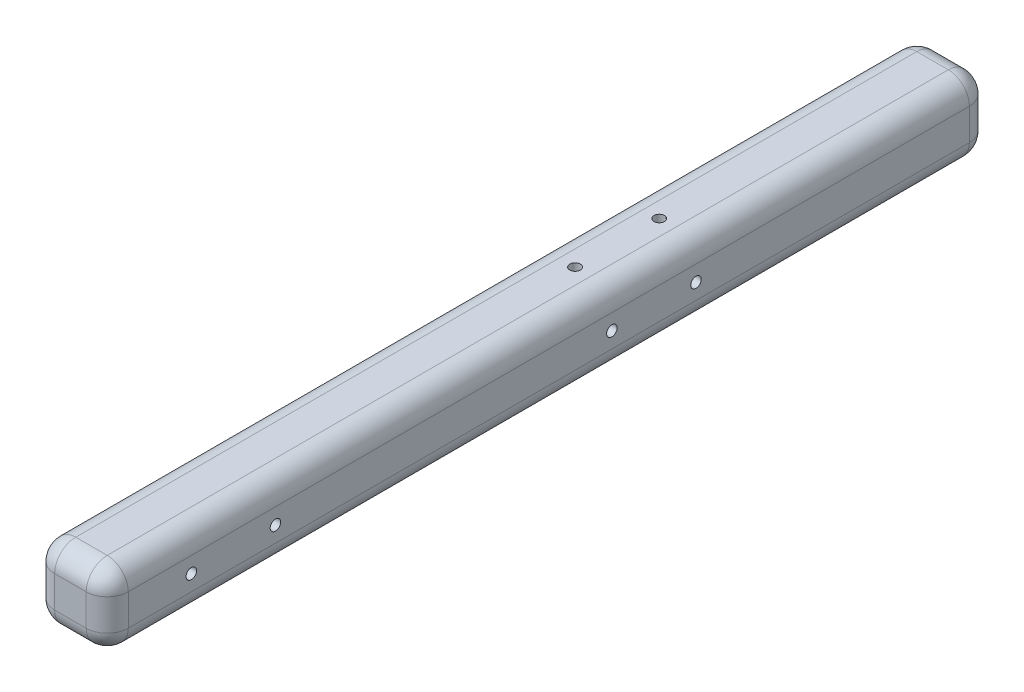
from build123d import *

# Parameters (mm, degrees)
BOSS_EXTRUDE1_DEPTH = 254
FILLET1_R           = 12.7
SKETCH2_R           = 3.175
CUT_EXTRUDE1_DEPTH  = 12.7
CIRPATTERN2_COUNT   = 2
CIRPATTERN2_ANGLE   = 90
BOSS_EXTRUDE2_DEPTH = 279.4
FILLET2_R           = 12.7
SKETCH5_R           = 3.175
CUT_EXTRUDE2_DEPTH  = 12.7


with BuildPart() as part:
    # Sketch1 → Boss-Extrude1 (new body)
    with BuildSketch(Plane.XY):
        with BuildLine():
            Line((-9.525, -22.225), (9.525, -22.225))
            ThreePointArc((9.525, -22.225), (18.505256121, -18.505256121), (22.225, -9.525))
            Line((22.225, -9.525), (22.225, 9.525))
            ThreePointArc((22.225, 9.525), (18.505256121, 18.505256121), (9.525, 22.225))
            Line((9.525, 22.225), (-9.525, 22.225))
            ThreePointArc((-9.525, 22.225), (-18.505256121, 18.505256121), (-22.225, 9.525))
            Line((-22.225, 9.525), (-22.225, -9.525))
            ThreePointArc((-22.225, -9.525), (-18.505256121, -18.505256121), (-9.525, -22.225))
        make_face()
    extrude(amount=BOSS_EXTRUDE1_DEPTH)

    # Fillet1
    fillet1_edges = [part.edges().sort_by_distance(p)[0] for p in [
        (0, -22.225, 0),
        (-18.505256121, -18.505256121, 0),
        (-22.225, 0, 0),
        (-18.505256121, 18.505256121, 0),
        (0, 22.225, 0),
        (18.505256121, 18.505256121, 0),
        (22.225, 0, 0),
        (18.505256121, -18.505256121, 0),
    ]]
    fillet(fillet1_edges, radius=FILLET1_R)

    # Sketch2 → Cut-Extrude1 (cut)
    with BuildSketch(Plane(origin=(0, 22.225, 0), x_dir=(1, 0, 0), z_dir=(0, 1, 0))):
        with Locations(Location((0, -177.8, 0), (0, 0, 270))):  # turned: the seam where the file's is
            Circle(SKETCH2_R)
        with Locations(Location((0, -228.6, 0), (0, 0, 270))):  # turned: the seam where the file's is
            Circle(SKETCH2_R)
    cut_extrude1 = extrude(amount=-CUT_EXTRUDE1_DEPTH, mode=Mode.SUBTRACT)

    # CirPattern2: Cut-Extrude1 ×2 about axis
    cirpattern2_axis = Axis((0, 0, 1052.131449431), (0, 0, -1))
    for i in range(1, CIRPATTERN2_COUNT):
        add(cut_extrude1.rotate(cirpattern2_axis, i * CIRPATTERN2_ANGLE / (CIRPATTERN2_COUNT - 1)), mode=Mode.SUBTRACT)

    # Sketch4 → Boss-Extrude2 (add)
    with BuildSketch(Plane.XY.offset(254)):
        with BuildLine():
            Line((-9.525, -22.225), (9.525, -22.225))
            ThreePointArc((9.525, -22.225), (18.505256121, -18.505256121), (22.225, -9.525))
            Line((22.225, -9.525), (22.225, 9.525))
            ThreePointArc((22.225, 9.525), (18.505256121, 18.505256121), (9.525, 22.225))
            Line((9.525, 22.225), (-9.525, 22.225))
            ThreePointArc((-9.525, 22.225), (-18.505256121, 18.505256121), (-22.225, 9.525))
            Line((-22.225, 9.525), (-22.225, -9.525))
            ThreePointArc((-22.225, -9.525), (-18.505256121, -18.505256121), (-9.525, -22.225))
        make_face()
    extrude(amount=BOSS_EXTRUDE2_DEPTH)

    # Fillet2
    fillet2_edges = [part.edges().sort_by_distance(p)[0] for p in [
        (-18.505256121, -18.505256121, 533.4),
        (0, -22.225, 533.4),
        (18.505256121, -18.505256121, 533.4),
        (22.225, 0, 533.4),
        (18.505256121, 18.505256121, 533.4),
        (0, 22.225, 533.4),
        (-18.505256121, 18.505256121, 533.4),
        (-22.225, 0, 533.4),
    ]]
    fillet(fillet2_edges, radius=FILLET2_R)

    # Sketch5 → Cut-Extrude2 (cut)
    with BuildSketch(Plane(origin=(22.225, 0, 0), x_dir=(0, 0, -1), z_dir=(1, 0, 0))):
        with Locations((-431.8, 0)):
            Circle(SKETCH5_R)
        with Locations((-482.6, 0)):
            Circle(SKETCH5_R)
    extrude(amount=-CUT_EXTRUDE2_DEPTH, mode=Mode.SUBTRACT)


solid = part.part
